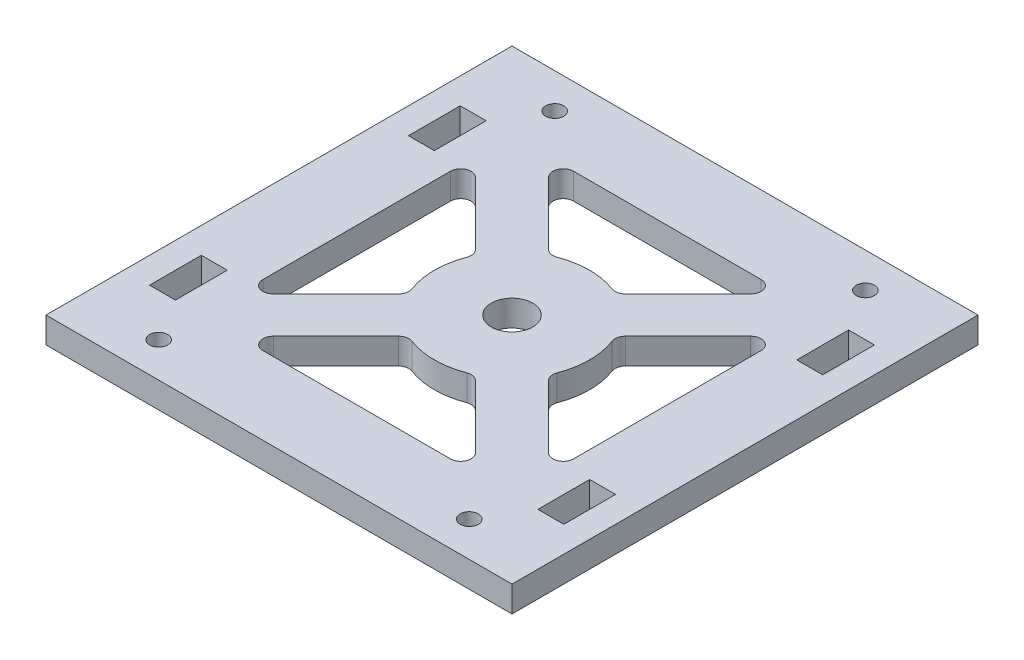
from build123d import *

# Parameters (mm, degrees)
SKETCH1_W               = 90
SKETCH1_H               = 90
SKETCH1_R               = 3.501345848
BOSS_EXTRUDE1_DEPTH     = 5
SKETCH2_R               = 1.75
SKETCH2_W               = 5
SKETCH2_H               = 10
CUT_EXTRUDE1_DEPTH      = 1
CUT_EXTRUDE1_DEPTH_BACK = 6
SKETCH3_R               = 4
CUT_EXTRUDE2_DEPTH      = 10


with BuildPart() as part:
    # Sketch1 → Boss-Extrude1 (new body)
    with BuildSketch(Plane(origin=(0, 0, 0), x_dir=(1, 0, 0), z_dir=(0, 1, 0))):
        Rectangle(SKETCH1_W, SKETCH1_H)
        Circle(SKETCH1_R, mode=Mode.SUBTRACT)
        with BuildLine():
            Line((-26.585786438, 19.514718626), (-14.489985056, 7.418917244))
            ThreePointArc((-14.489985056, 7.418917244), (-13.949056578, 6.425915745), (-14.033116428, 5.298267955))
            ThreePointArc((-14.033116428, 5.298267955), (-15, 0), (-14.033116428, -5.298267955))
            ThreePointArc((-14.033116428, -5.298267955), (-13.949056578, -6.425915745), (-14.489985056, -7.418917244))
            Line((-14.489985056, -7.418917244), (-26.585786438, -19.514718626))
            ThreePointArc((-26.585786438, -19.514718626), (-28.765366865, -19.948264128), (-30, -18.100505063))
            Line((-30, -18.100505063), (-30, 18.100505063))
            ThreePointArc((-30, 18.100505063), (-28.765366865, 19.948264128), (-26.585786438, 19.514718626))
        make_face(mode=Mode.SUBTRACT)
        with BuildLine():
            Line((-18.100505063, 30), (18.100505063, 30))
            ThreePointArc((18.100505063, 30), (19.948264128, 28.765366865), (19.514718626, 26.585786438))
            Line((19.514718626, 26.585786438), (7.418917244, 14.489985056))
            ThreePointArc((7.418917244, 14.489985056), (6.425915745, 13.949056578), (5.298267955, 14.033116428))
            ThreePointArc((5.298267955, 14.033116428), (0, 15), (-5.298267955, 14.033116428))
            ThreePointArc((-5.298267955, 14.033116428), (-6.425915745, 13.949056578), (-7.418917244, 14.489985056))
            Line((-7.418917244, 14.489985056), (-19.514718626, 26.585786438))
            ThreePointArc((-19.514718626, 26.585786438), (-19.948264128, 28.765366865), (-18.100505063, 30))
        make_face(mode=Mode.SUBTRACT)
        with BuildLine():
            Line((30, 18.100505063), (30, -18.100505063))
            ThreePointArc((30, -18.100505063), (28.765366865, -19.948264128), (26.585786438, -19.514718626))
            Line((26.585786438, -19.514718626), (14.489985056, -7.418917244))
            ThreePointArc((14.489985056, -7.418917244), (13.949056578, -6.425915745), (14.033116428, -5.298267955))
            ThreePointArc((14.033116428, -5.298267955), (15, 0), (14.033116428, 5.298267955))
            ThreePointArc((14.033116428, 5.298267955), (13.949056578, 6.425915745), (14.489985056, 7.418917244))
            Line((14.489985056, 7.418917244), (26.585786438, 19.514718626))
            ThreePointArc((26.585786438, 19.514718626), (28.765366865, 19.948264128), (30, 18.100505063))
        make_face(mode=Mode.SUBTRACT)
        with BuildLine():
            Line((19.514718626, -26.585786438), (7.418917244, -14.489985056))
            ThreePointArc((7.418917244, -14.489985056), (6.425915745, -13.949056578), (5.298267955, -14.033116428))
            ThreePointArc((5.298267955, -14.033116428), (0, -15), (-5.298267955, -14.033116428))
            ThreePointArc((-5.298267955, -14.033116428), (-6.425915745, -13.949056578), (-7.418917244, -14.489985056))
            Line((-7.418917244, -14.489985056), (-19.514718626, -26.585786438))
            ThreePointArc((-19.514718626, -26.585786438), (-19.948264128, -28.765366865), (-18.100505063, -30))
            Line((-18.100505063, -30), (18.100505063, -30))
            ThreePointArc((18.100505063, -30), (19.948264128, -28.765366865), (19.514718626, -26.585786438))
        make_face(mode=Mode.SUBTRACT)
    extrude(amount=BOSS_EXTRUDE1_DEPTH)

    # Sketch2 → Cut-Extrude1 (cut, two sides)
    with BuildSketch(Plane(origin=(0, 5, 0), x_dir=(1, 0, 0), z_dir=(0, 1, 0))) as cut_extrude1_sk:
        with Locations((-30, -38.25)):
            Circle(SKETCH2_R)
        with Locations((30, -38.25)):
            Circle(SKETCH2_R)
        with Locations((30, 38.25)):
            Circle(SKETCH2_R)
        with Locations((-30, 38.25)):
            Circle(SKETCH2_R)
        with Locations((37.5, 25)):
            Rectangle(SKETCH2_W, SKETCH2_H)
        with Locations((37.5, -25)):
            Rectangle(SKETCH2_W, SKETCH2_H)
        with Locations((-37.5, -25)):
            Rectangle(SKETCH2_W, SKETCH2_H)
        with Locations((-37.5, 25)):
            Rectangle(SKETCH2_W, SKETCH2_H)
    extrude(amount=CUT_EXTRUDE1_DEPTH, mode=Mode.SUBTRACT)
    extrude(cut_extrude1_sk.sketch, amount=-CUT_EXTRUDE1_DEPTH_BACK, mode=Mode.SUBTRACT)

    # Sketch3 → Cut-Extrude2 (cut)
    with BuildSketch(Plane(origin=(0, 5, 0), x_dir=(1, 0, 0), z_dir=(0, 1, 0))):
        Circle(SKETCH3_R)
    extrude(amount=-CUT_EXTRUDE2_DEPTH, mode=Mode.SUBTRACT)


solid = part.part
